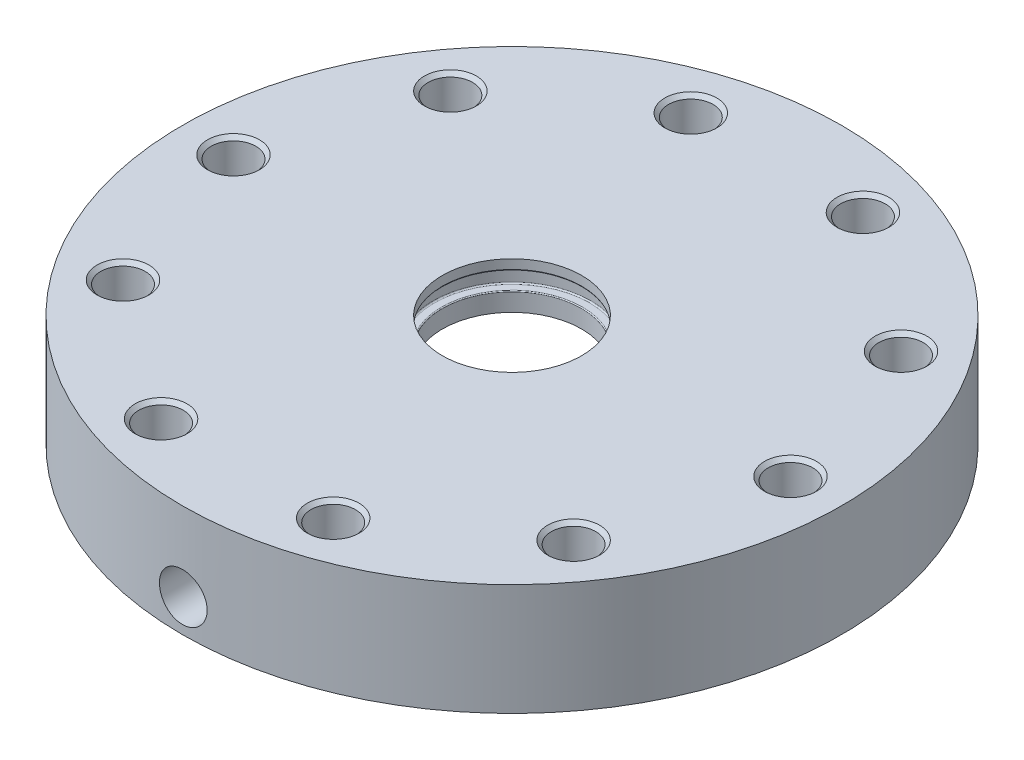
from build123d import *

# Parameters (mm, degrees)
HOLE1_D                          = 6.096
HOLE1_DEPTH                      = 15.2654
CIRPATTERN1_COUNT                = 10
FILLET1_R                        = 1.27
F_5_16_18_TAPPED_HOLE1_D         = 6.5278
F_5_16_18_TAPPED_HOLE1_DEPTH     = 10.16
F_5_16_18_TAPPED_HOLE1_TIP       = 1.961148974
F_1_8_0_125_DIAMETER_HOLE1_D     = 3.175
F_1_8_0_125_DIAMETER_HOLE1_DEPTH = 14.986
F_1_8_0_125_DIAMETER_HOLE1_TIP   = 0.953866233
SKETCH20_W                       = 1.27
SKETCH20_H                       = 2.413
FILLET2_R                        = 0.1778
FILLET3_R                        = 0.127
CHAMFER1_SIZE                    = 0.508


with BuildPart() as part:
    # Sketch1 → Revolve1 (revolve)
    with BuildSketch(Plane.XY):
        Polygon((9.525, 0), (45.085, 0), (45.085, -15.2654), (24.13, -15.2654), (24.13, -6.35), (9.525, -6.35), align=None)
    revolve(axis=Axis((0, 0, 0), (0, 1, 0)))

    # Hole1
    with Locations(Plane(origin=(0, 0, 0), x_dir=(1, 0, 0), z_dir=(0, 1, 0))):
        with Locations((38.1, 0)):
            hole1 = Hole(HOLE1_D / 2, depth=HOLE1_DEPTH)

    # CirPattern1: Hole1 ×10 about axis
    cirpattern1_axis = Axis((0, 0, 0), (0, 1, 0))
    for i in range(1, CIRPATTERN1_COUNT):
        add(hole1.rotate(cirpattern1_axis, i * 360 / CIRPATTERN1_COUNT), mode=Mode.SUBTRACT)

    # Fillet1
    fillet1_edges = [part.edges().sort_by_distance(p)[0] for p in [
        (-24.13, -6.35, 0),
    ]]
    fillet(fillet1_edges, radius=FILLET1_R)

    # 5/16-18 Tapped Hole1
    with Locations(Plane.XY.offset(45.085)):
        with Locations((0, -10.795)):
            Hole(F_5_16_18_TAPPED_HOLE1_D / 2, depth=F_5_16_18_TAPPED_HOLE1_DEPTH)
            with Locations((0, 0, -(F_5_16_18_TAPPED_HOLE1_DEPTH + F_5_16_18_TAPPED_HOLE1_TIP / 2))):  # 118° drill point
                Cone(0, F_5_16_18_TAPPED_HOLE1_D / 2, F_5_16_18_TAPPED_HOLE1_TIP, mode=Mode.SUBTRACT)

    # 1/8 (0.125) Diameter Hole1
    with Locations(Plane.XY.offset(34.925)):
        with Locations((0, -10.795)):
            Hole(F_1_8_0_125_DIAMETER_HOLE1_D / 2, depth=F_1_8_0_125_DIAMETER_HOLE1_DEPTH)
            with Locations((0, 0, -(F_1_8_0_125_DIAMETER_HOLE1_DEPTH + F_1_8_0_125_DIAMETER_HOLE1_TIP / 2))):  # 118° drill point
                Cone(0, F_1_8_0_125_DIAMETER_HOLE1_D / 2, F_1_8_0_125_DIAMETER_HOLE1_TIP, mode=Mode.SUBTRACT)

    # Sketch20 → Cut-Revolve1 (revolve, cut)
    with BuildSketch(Plane.XY):
        with Locations((10.16, -2.6035)):
            Rectangle(SKETCH20_W, SKETCH20_H)
    revolve(axis=Axis((0, 0, 0), (0, 1, 0)), mode=Mode.SUBTRACT)

    # Fillet2
    fillet2_edges = [part.edges().sort_by_distance(p)[0] for p in [
        (-10.795, -1.397, 0),
        (-10.795, -3.81, 0),
    ]]
    fillet(fillet2_edges, radius=FILLET2_R)

    # Fillet3
    fillet3_edges = [part.edges().sort_by_distance(p)[0] for p in [
        (-9.525, -1.397, 0),
        (-9.525, -3.81, 0),
    ]]
    fillet(fillet3_edges, radius=FILLET3_R)

    # Chamfer1
    chamfer1_edges = [part.edges().sort_by_distance(p)[0] for p in [
        (41.148, 0, 0),
        (41.148, -15.2654, 0),
        (33.289431285, 0, 24.186187561),
        (33.289431285, -15.2654, 24.186187561),
        (12.715431285, 0, 39.134073533),
        (12.715431285, -15.2654, 39.134073533),
        (-12.715431285, 0, 39.134073533),
        (-12.715431285, -15.2654, 39.134073533),
        (-33.289431285, 0, 24.186187561),
        (-33.289431285, -15.2654, 24.186187561),
        (-41.148, 0, 0),
        (-41.148, -15.2654, 0),
        (-33.289431285, 0, -24.186187561),
        (-33.289431285, -15.2654, -24.186187561),
        (-12.715431285, 0, -39.134073533),
        (-12.715431285, -15.2654, -39.134073533),
        (12.715431285, 0, -39.134073533),
        (12.715431285, -15.2654, -39.134073533),
        (33.289431285, 0, -24.186187561),
        (33.289431285, -15.2654, -24.186187561),
    ]]
    chamfer(chamfer1_edges, length=CHAMFER1_SIZE)


solid = part.part
